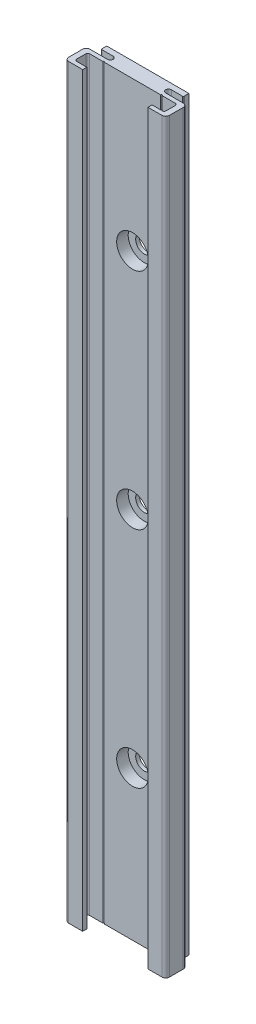
from build123d import *

# Parameters (mm, degrees)
BOSS_EXTRUDE1_DEPTH                              = 200
CUT_EXTRUDE1_DEPTH                               = 201
F_0_4_0_4_DIAMETER_HOLE1_D                       = 0.4
F_0_4_0_4_DIAMETER_HOLE1_DEPTH                   = 200
CBORE_FOR_M4_HEX_HEAD_MACHINE_SCREW1_D           = 4.5
CBORE_FOR_M4_HEX_HEAD_MACHINE_SCREW1_DEPTH       = 4.1
CBORE_FOR_M4_HEX_HEAD_MACHINE_SCREW1_CBORE_D     = 8.5
CBORE_FOR_M4_HEX_HEAD_MACHINE_SCREW1_CBORE_DEPTH = 3.1
FILLET1_R                                        = 0.2
FILLET2_R                                        = 0.5
FILLET3_R                                        = 1


with BuildPart() as part:
    # Sketch1 → Boss-Extrude1 (new body)
    with BuildSketch(Plane(origin=(0, 300, 0), x_dir=(1, 0, 0), z_dir=(0, 1, 0))):
        with BuildLine():
            Line((-13.5, -3), (-13.5, -8.7))
            Line((-13.5, -8.7), (13.5, -8.7))
            Line((13.5, -8.7), (13.5, -3))
            Line((13.5, -3), (7.8, -3))
            ThreePointArc((7.8, -3), (7.05, -2.25), (7.8, -1.5))
            Line((7.8, -1.5), (11, -1.5))
            Line((11, -1.5), (11, 0))
            Line((11, 0), (-11, 0))
            Line((-11, 0), (-11, -1.5))
            Line((-11, -1.5), (-7.8, -1.5))
            ThreePointArc((-7.8, -1.5), (-7.05, -2.25), (-7.8, -3))
            Line((-7.8, -3), (-13.5, -3))
        make_face()
    extrude(amount=-BOSS_EXTRUDE1_DEPTH)

    # Sketch2 → Cut-Extrude1 (cut, through all)
    with BuildSketch(Plane.XZ.offset(-100)):
        Polygon((8.75, 8.7), (-8.75, 8.7), (-8.75, 7.6), (-12, 7.6), (-12, 4.1), (12, 4.1), (12, 7.6), (8.75, 7.6), align=None)
    extrude(amount=-CUT_EXTRUDE1_DEPTH, mode=Mode.SUBTRACT)

    # Ø0.4 (0.4) Diameter Hole1
    with Locations(Plane(origin=(0, 300, 0), x_dir=(1, 0, 0), z_dir=(0, 1, 0))):
        with Locations((-7.75, -4.1), (7.75, -4.1)):
            Hole(F_0_4_0_4_DIAMETER_HOLE1_D / 2, depth=F_0_4_0_4_DIAMETER_HOLE1_DEPTH)

    # CBORE for M4 Hex Head Machine Screw1
    with Locations(Plane.XY.offset(4.1)):
        with Locations((0, 260), (0, 200), (0, 140), (0, 80), (0, 20)):
            CounterBoreHole(CBORE_FOR_M4_HEX_HEAD_MACHINE_SCREW1_D / 2, CBORE_FOR_M4_HEX_HEAD_MACHINE_SCREW1_CBORE_D / 2, CBORE_FOR_M4_HEX_HEAD_MACHINE_SCREW1_CBORE_DEPTH, depth=CBORE_FOR_M4_HEX_HEAD_MACHINE_SCREW1_DEPTH)

    # Fillet1
    fillet1_edges = [part.edges().sort_by_distance(p)[0] for p in [
        (-11, 200, 1.5),
        (11, 200, 1.5),
    ]]
    fillet(fillet1_edges, radius=FILLET1_R)

    # Fillet2
    fillet2_edges = [part.edges().sort_by_distance(p)[0] for p in [
        (12, 200, 7.6),
        (12, 200, 4.1),
        (-12, 200, 4.1),
        (-12, 200, 7.6),
    ]]
    fillet(fillet2_edges, radius=FILLET2_R)

    # Fillet3
    fillet3_edges = [part.edges().sort_by_distance(p)[0] for p in [
        (13.5, 200, 3),
        (13.5, 200, 8.7),
        (-13.5, 200, 8.7),
        (-13.5, 200, 3),
    ]]
    fillet(fillet3_edges, radius=FILLET3_R)


solid = part.part
